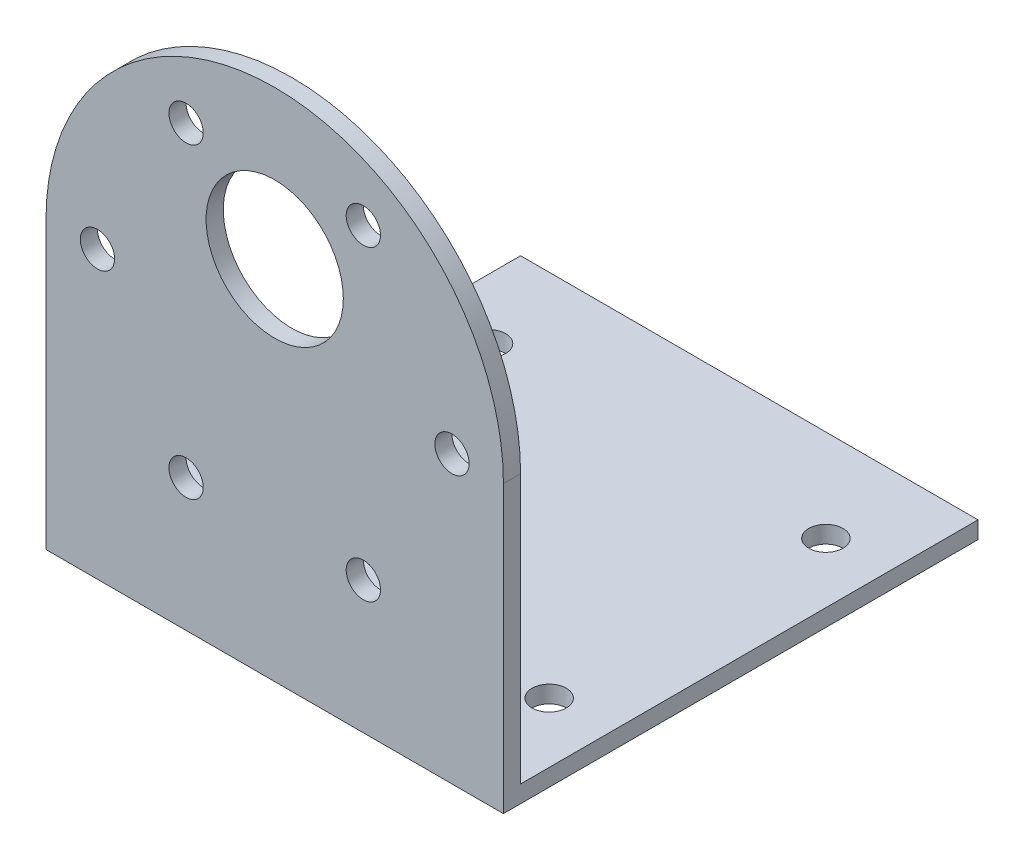
from build123d import *

# Parameters (mm, degrees)
SKETCH_1_R          = 1.5
SKETCH_1_R_2        = 6
EXTRUDE_1_DEPTH     = 1.5
SKETCH_1_3_W        = 40
SKETCH_1_3_H        = 1.5
EXTRUDE_2_DEPTH     = 40
SKETCH_2_R          = 1.5
CUT_EXTRUDE_1_DEPTH = 63.387899468


with BuildPart() as part:
    # 草图1 → 凸台-拉伸1 (new body)
    with BuildSketch(Plane.XY):
        with BuildLine():
            ThreePointArc((20, 0), (0, 20), (-20, 0))
            Line((-20, 0), (-20, -25))
            Line((-20, -25), (20, -25))
            Line((20, -25), (20, 0))
        make_face()
        with Locations((-7.75, -13.423393759)):
            Circle(SKETCH_1_R, mode=Mode.SUBTRACT)
        with Locations((7.75, -13.423393759)):
            Circle(SKETCH_1_R, mode=Mode.SUBTRACT)
        with Locations((-15.5, 0)):
            Circle(SKETCH_1_R, mode=Mode.SUBTRACT)
        with Locations((-7.75, 13.423393759)):
            Circle(SKETCH_1_R, mode=Mode.SUBTRACT)
        with Locations((0, 7)):
            Circle(SKETCH_1_R_2, mode=Mode.SUBTRACT)
        with Locations((15.5, 0)):
            Circle(SKETCH_1_R, mode=Mode.SUBTRACT)
        with Locations((7.75, 13.423393759)):
            Circle(SKETCH_1_R, mode=Mode.SUBTRACT)
    extrude(amount=EXTRUDE_1_DEPTH)

    # 草图1<3> → 凸台-拉伸2 (add)
    with BuildSketch(Plane.XY):
        with Locations((0, -24.25)):
            Rectangle(SKETCH_1_3_W, SKETCH_1_3_H)
    extrude(amount=-EXTRUDE_2_DEPTH)

    # 草图2 → 切除-拉伸1 (cut, through all)
    with BuildSketch(Plane(origin=(0, -23.5, 0), x_dir=(1, 0, 0), z_dir=(0, 1, 0))):
        with Locations((-14.75, 31.95)):
            Circle(SKETCH_2_R)
        with Locations((-14.75, 7.75)):
            Circle(SKETCH_2_R)
        with Locations((14.75, 7.75)):
            Circle(SKETCH_2_R)
        with Locations((14.75, 31.95)):
            Circle(SKETCH_2_R)
    extrude(amount=-CUT_EXTRUDE_1_DEPTH, mode=Mode.SUBTRACT)


solid = part.part
